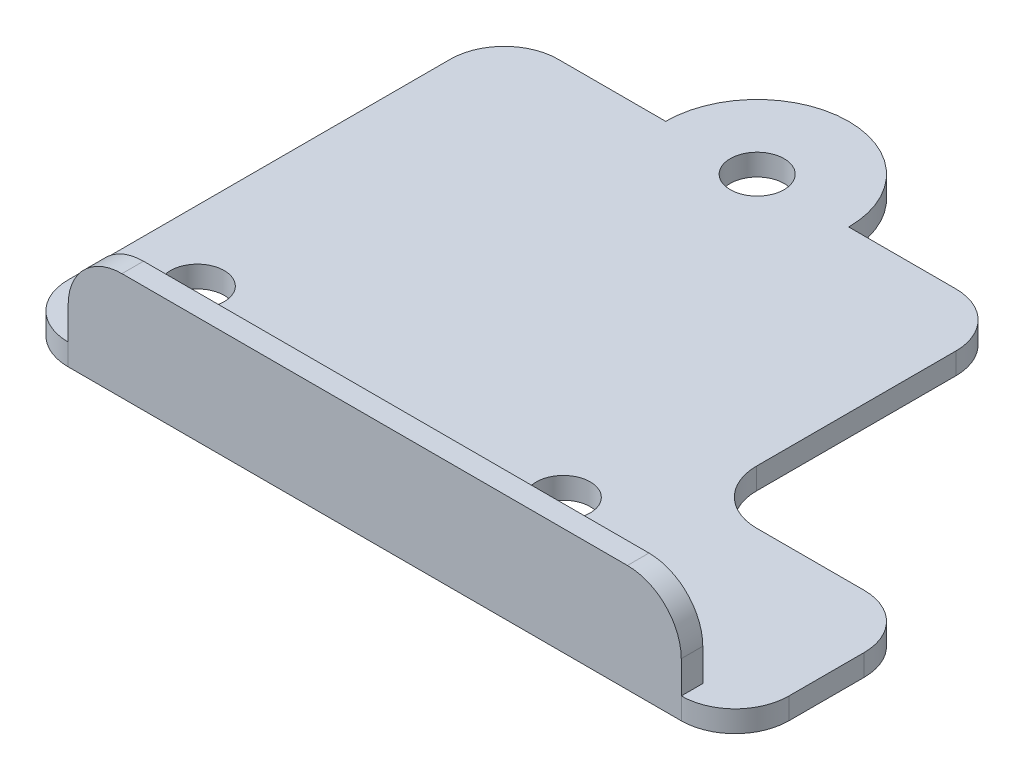
from build123d import *

# Parameters (mm, degrees)
SKETCH1_R           = 2.5
BOSS_EXTRUDE1_DEPTH = 2
SKETCH2_W           = 56.957260919
SKETCH2_H           = 2
BOSS_EXTRUDE2_DEPTH = 8
FILLET1_R           = 5


with BuildPart() as part:
    # Sketch1 → Boss-Extrude1 (new body)
    with BuildSketch(Plane(origin=(0, 0, 0), x_dir=(1, 0, 0), z_dir=(0, 1, 0))):
        with BuildLine():
            Line((-18.5, 25.846586538), (-8.5, 25.846586538))
            ThreePointArc((-8.5, 25.846586538), (0, 34.346586538), (8.5, 25.846586538))
            Line((8.5, 25.846586538), (18.457260919, 25.846586538))
            ThreePointArc((18.457260919, 25.846586538), (21.992794825, 24.382120444), (23.457260919, 20.846586538))
            Line((23.457260919, 20.846586538), (23.457260919, 2.336586538))
            ThreePointArc((23.457260919, 2.336586538), (24.921727013, -1.198947367), (28.457260919, -2.663413462))
            Line((28.457260919, -2.663413462), (38.457260919, -2.663413462))
            ThreePointArc((38.457260919, -2.663413462), (41.992794825, -4.127879556), (43.457260919, -7.663413462))
            Line((43.457260919, -7.663413462), (43.457260919, -14.663413462))
            ThreePointArc((43.457260919, -14.663413462), (41.992794825, -18.198947367), (38.457260919, -19.663413462))
            Line((38.457260919, -19.663413462), (23.457260919, -19.663413462))
            Line((23.457260919, -19.663413462), (0, -19.663413462))
            Line((0, -19.663413462), (-18.5, -19.663413462))
            ThreePointArc((-18.5, -19.663413462), (-22.035533906, -18.198947367), (-23.5, -14.663413462))
            Line((-23.5, -14.663413462), (-23.5, 20.846586538))
            ThreePointArc((-23.5, 20.846586538), (-22.035533906, 24.382120444), (-18.5, 25.846586538))
        make_face()
        with Locations((-17, -9.163413462)):
            Circle(SKETCH1_R, mode=Mode.SUBTRACT)
        with Locations((17, -9.163413462)):
            Circle(SKETCH1_R, mode=Mode.SUBTRACT)
        with Locations((0, 25.846586538)):
            Circle(SKETCH1_R, mode=Mode.SUBTRACT)
    extrude(amount=BOSS_EXTRUDE1_DEPTH)

    # Sketch2 → Boss-Extrude2 (add)
    with BuildSketch(Plane(origin=(0, 2, 0), x_dir=(1, 0, 0), z_dir=(0, 1, 0))):
        with Locations((9.978630459, -18.663413462)):
            Rectangle(SKETCH2_W, SKETCH2_H)
    extrude(amount=BOSS_EXTRUDE2_DEPTH)

    # Fillet1
    fillet1_edges = [part.edges().sort_by_distance(p)[0] for p in [
        (-18.5, 10, 18.663413462),
        (38.457260919, 10, 18.663413462),
    ]]
    fillet(fillet1_edges, radius=FILLET1_R)


solid = part.part
